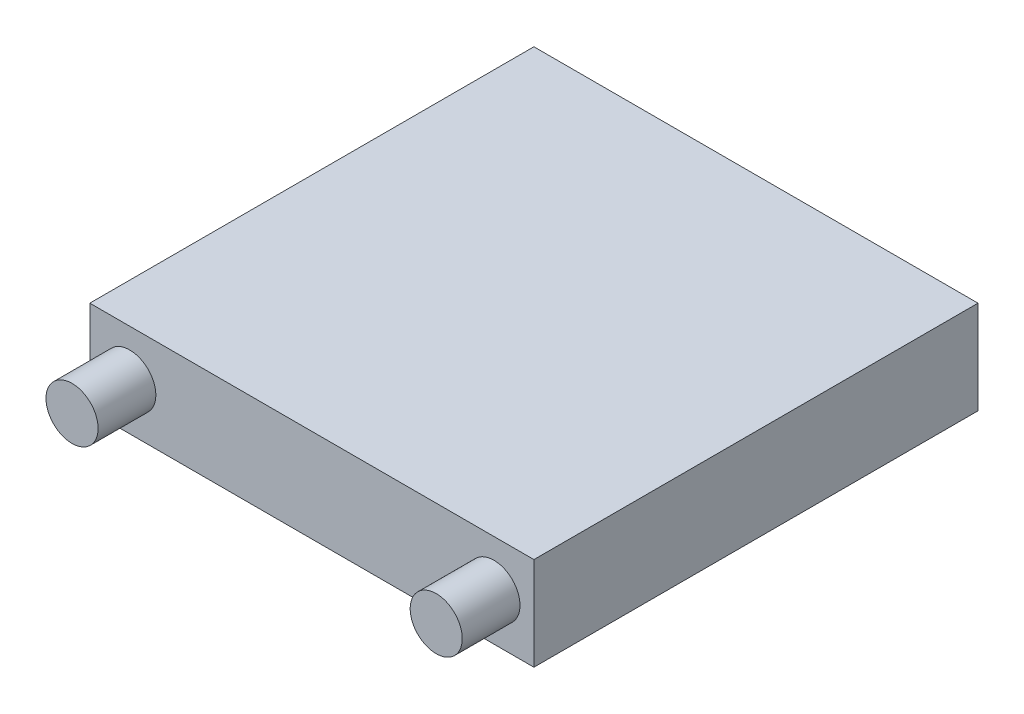
from build123d import *

# Parameters (mm, degrees)
SKETCH_1_W      = 20
SKETCH_1_H      = 20
EXTRUDE_1_DEPTH = 4.2
SKETCH_2_R      = 1.173131764
EXTRUDE_2_DEPTH = 12.6


with BuildPart() as part:
    # 草图1 → 凸台-拉伸1 (new body)
    with BuildSketch(Plane(origin=(0, 0, 0), x_dir=(1, 0, 0), z_dir=(0, 1, 0))):
        Rectangle(SKETCH_1_W, SKETCH_1_H)
    extrude(amount=EXTRUDE_1_DEPTH)

    # 草图2 → 凸台-拉伸2 (add)
    with BuildSketch(Plane.XY):
        with Locations((-8.2, 2.1)):
            Circle(SKETCH_2_R)
        with Locations((8.2, 2.1)):
            Circle(SKETCH_2_R)
    extrude(amount=EXTRUDE_2_DEPTH)


solid = part.part
